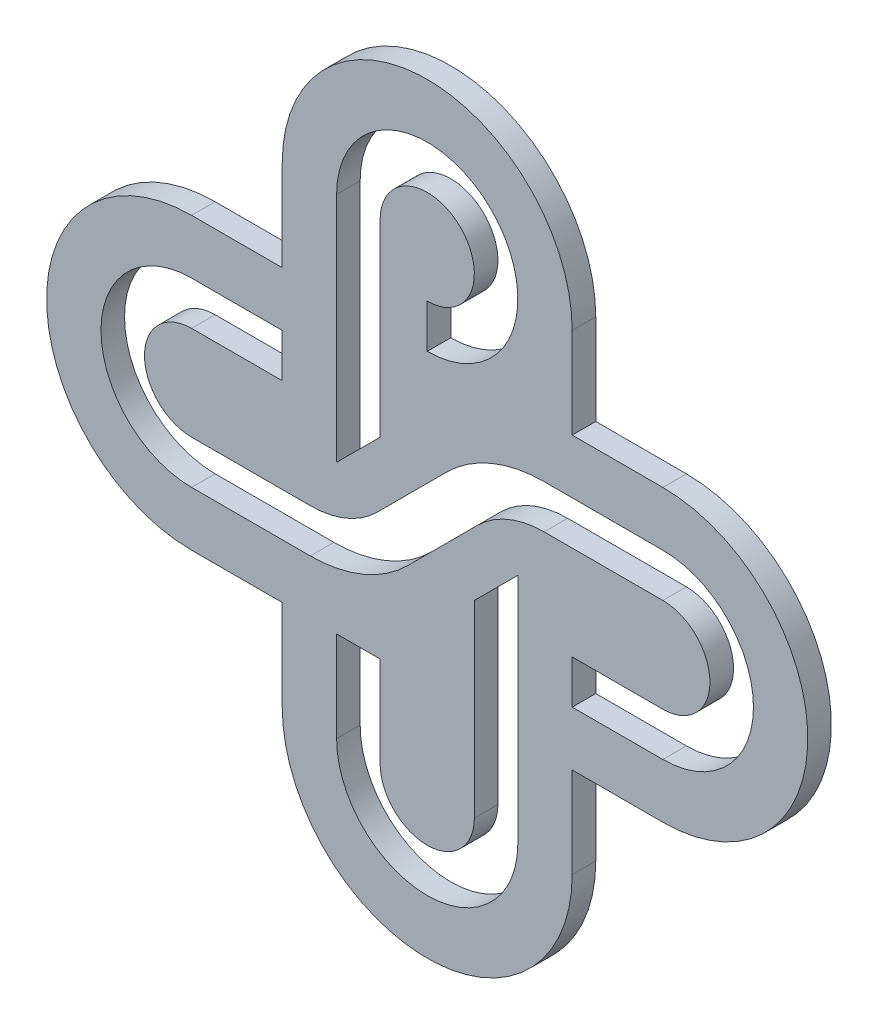
from build123d import *

# Parameters (mm, degrees)
BOSS_EXTRUDE1_DEPTH = 3.175


with BuildPart() as part:
    # Sketch2 → Boss-Extrude1 (new body)
    with BuildSketch(Plane.XY):
        with BuildLine():
            Line((19.538461538, 19.538461538), (31.75, 19.538461538))
            ThreePointArc((31.75, 19.538461538), (51.288461538, 0), (31.75, -19.538461538))
            Line((31.75, -19.538461538), (19.538461538, -19.538461538))
            Line((19.538461538, -19.538461538), (19.538461538, -31.75))
            ThreePointArc((19.538461538, -31.75), (0, -51.288461538), (-19.538461538, -31.75))
            Line((-19.538461538, -31.75), (-19.538461538, -19.538461538))
            Line((-19.538461538, -19.538461538), (-31.75, -19.538461538))
            ThreePointArc((-31.75, -19.538461538), (-51.288461538, 0), (-31.75, 19.538461538))
            Line((-31.75, 19.538461538), (-19.538461538, 19.538461538))
            Line((-19.538461538, 19.538461538), (-19.538461538, 31.75))
            ThreePointArc((-19.538461538, 31.75), (0, 51.288461538), (19.538461538, 31.75))
            Line((19.538461538, 31.75), (19.538461538, 19.538461538))
        make_face()
        with BuildLine():
            Line((-31.75, 12.211538462), (-19.538461538, 12.211538462))
            Line((-19.538461538, 12.211538462), (-19.538461538, 6.35))
            Line((-19.538461538, 6.35), (-31.75, 6.35))
            ThreePointArc((-31.75, 6.35), (-38.1, 0), (-31.75, -6.35))
            Line((-31.75, -6.35), (-15.755245836, -6.35))
            ThreePointArc((-15.755245836, -6.35), (-10.895166245, -5.383270063), (-6.774989715, -2.630256121))
            Line((-6.774989715, -2.630256121), (2.630256121, 6.774989715))
            ThreePointArc((2.630256121, 6.774989715), (8.652052588, 10.798625477), (15.755245836, 12.211538462))
            Line((15.755245836, 12.211538462), (31.75, 12.211538462))
            ThreePointArc((31.75, 12.211538462), (43.961538462, 0), (31.75, -12.211538462))
            Line((31.75, -12.211538462), (19.538461538, -12.211538462))
            Line((19.538461538, -12.211538462), (19.538461538, -6.35))
            Line((19.538461538, -6.35), (31.75, -6.35))
            ThreePointArc((31.75, -6.35), (38.1, 0), (31.75, 6.35))
            Line((31.75, 6.35), (15.755245836, 6.35))
            ThreePointArc((15.755245836, 6.35), (10.895166245, 5.383270063), (6.774989715, 2.630256121))
            Line((6.774989715, 2.630256121), (-2.630256121, -6.774989715))
            ThreePointArc((-2.630256121, -6.774989715), (-8.652052588, -10.798625477), (-15.755245836, -12.211538462))
            Line((-15.755245836, -12.211538462), (-31.75, -12.211538462))
            ThreePointArc((-31.75, -12.211538462), (-43.961538462, 0), (-31.75, 12.211538462))
        make_face(mode=Mode.SUBTRACT)
        with BuildLine():
            Line((-6.35, -31.75), (-6.35, -19.538461538))
            Line((-6.35, -19.538461538), (-12.211538462, -19.538461538))
            Line((-12.211538462, -19.538461538), (-12.211538462, -31.75))
            ThreePointArc((-12.211538462, -31.75), (0, -43.961538462), (12.211538462, -31.75))
            Line((12.211538462, -31.75), (12.211538462, -0.488461538))
            Line((12.211538462, -0.488461538), (6.35, -6.35))
            Line((6.35, -6.35), (6.35, -31.75))
            ThreePointArc((6.35, -31.75), (0, -38.1), (-6.35, -31.75))
        make_face(mode=Mode.SUBTRACT)
        with BuildLine():
            Line((0, 25.4), (0, 19.538461538))
            ThreePointArc((0, 19.538461538), (8.634861655, 40.384861655), (-12.211538462, 31.75))
            Line((-12.211538462, 31.75), (-12.211538462, 0.488461538))
            Line((-12.211538462, 0.488461538), (-6.35, 6.35))
            Line((-6.35, 6.35), (-6.35, 31.75))
            ThreePointArc((-6.35, 31.75), (4.490128061, 36.240128061), (0, 25.4))
        make_face(mode=Mode.SUBTRACT)
    extrude(amount=BOSS_EXTRUDE1_DEPTH)


solid = part.part
